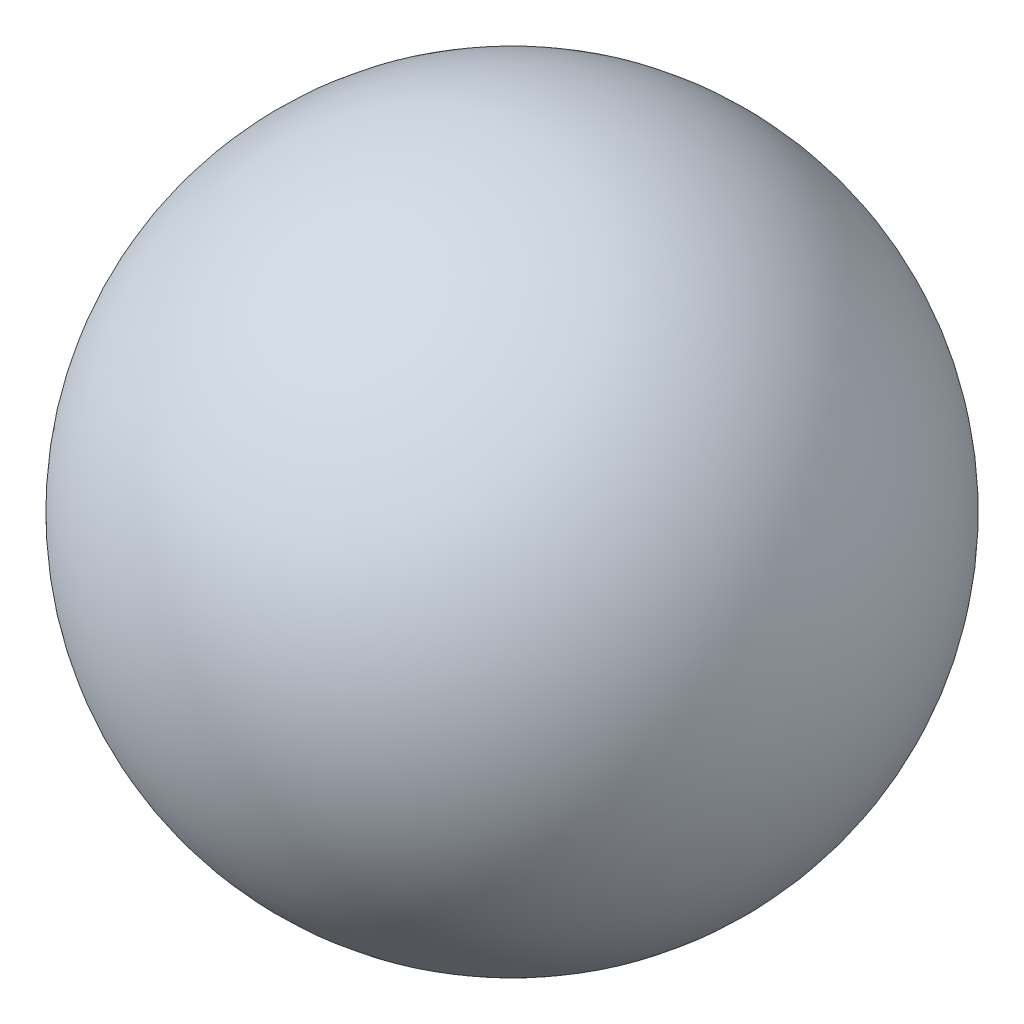
from build123d import *


with BuildPart() as part:
    # Sketch1 → Revolve1 (revolve)
    with BuildSketch(Plane.XY):
        with BuildLine():
            Line((0, 0.5), (0, -0.5))
            ThreePointArc((0, -0.5), (-0.5, 0), (0, 0.5))
        make_face()
    revolve(axis=Axis((0, 0.5, 0), (0, -1, 0)))


solid = part.part
